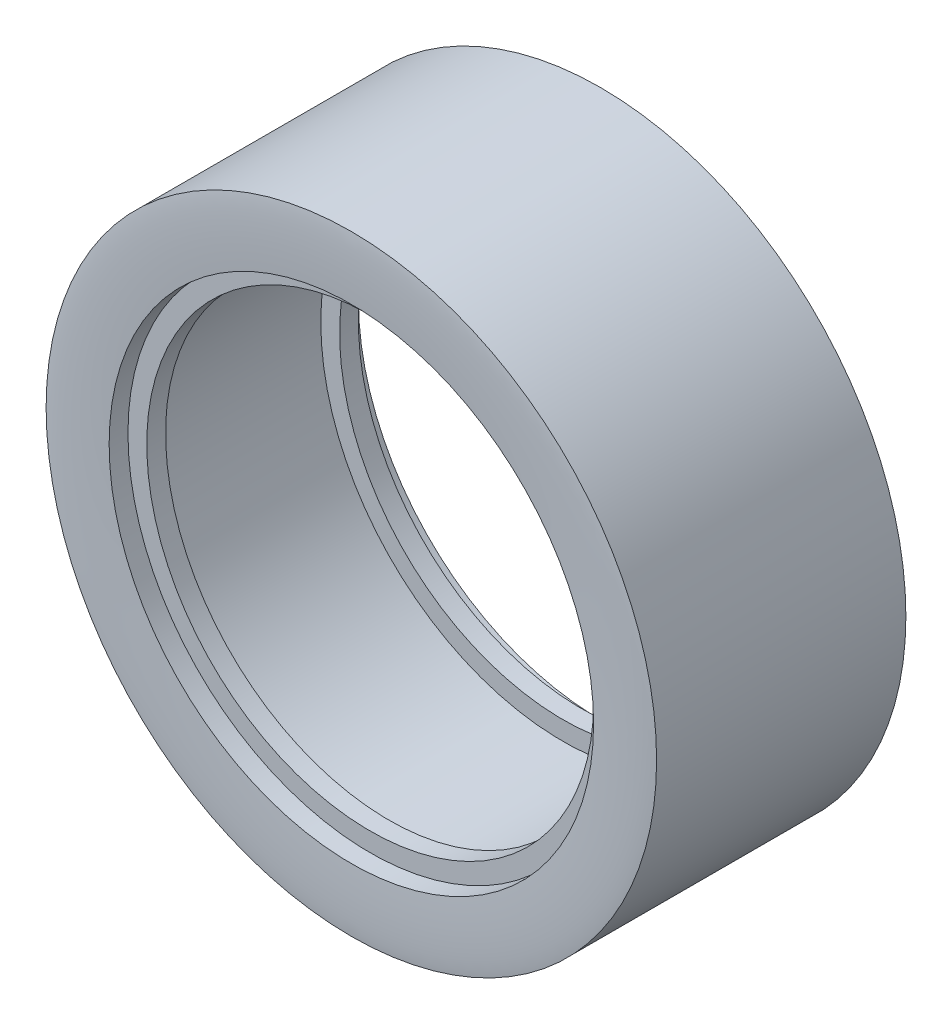
from build123d import *


with BuildPart() as part:
    # Sketch1 → Revolve1 (revolve)
    with BuildSketch(Plane(origin=(0, 0, 0), x_dir=(1, 0, 0), z_dir=(0, 1, 0))):
        with BuildLine():
            Line((25.75, 226.600121105), (25.75, 224.600121105))
            Line((25.75, 224.600121105), (23.75, 224.600121105))
            Line((23.75, 224.600121105), (23.75, 222.600121105))
            Line((23.75, 222.600121105), (25.75, 222.600121105))
            Line((25.75, 222.600121105), (25.75, 204.100121105))
            Line((25.75, 204.100121105), (23.75, 204.100121105))
            Line((23.75, 204.100121105), (23.75, 202.100121105))
            Line((23.75, 202.100121105), (25.75, 202.100121105))
            Line((25.75, 202.100121105), (25.75, 200.100121105))
            add(Edge.make_bspline(
                [(25.75, 200.100121105), (28.665236828, 199.927378107), (31.106495402, 199.927378107), (32.45, 200.100121105)],
                knots=[0, 0, 0, 0, 1, 1, 1, 1], degree=3))
            Line((32.45, 200.100121105), (32.45, 226.600121105))
            add(Edge.make_bspline(
                [(25.75, 226.600121105), (28.665236828, 226.772864103), (31.106495402, 226.772864103), (32.45, 226.600121105)],
                knots=[0, 0, 0, 0, 1, 1, 1, 1], degree=3))
        make_face()
    revolve(axis=Axis((0, 0, 0), (0, 0, -1)))


solid = part.part
